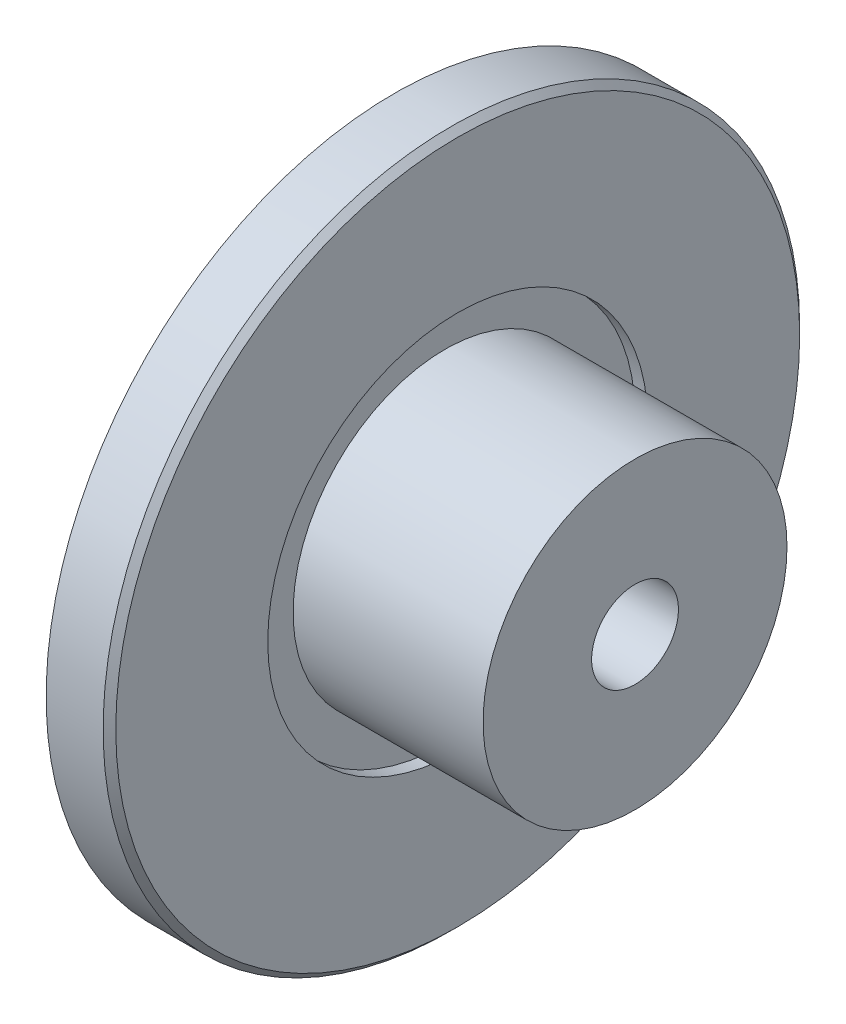
from build123d import *
from build123d.topology import SkipClean

# Parameters (mm, degrees)
SKETCH1_R               = 27.5
BOSS_EXTRUDE1_DEPTH     = 4
SKETCH2_R               = 27.5
SKETCH2_R_2             = 15
BOSS_EXTRUDE2_DEPTH     = 1
CUT_EXTRUDE1_DEPTH      = 40.210967853
CUT_EXTRUDE1_DEPTH_BACK = 40.210967853
SKETCH3_R               = 3.429
SKETCH4_R               = 12
SKETCH4_R_2             = 3.429
BOSS_EXTRUDE3_DEPTH     = 15
CHAMFER1_SIZE           = 0.5


with BuildPart() as part:
    # Sketch1 → Boss-Extrude1 (new body)
    with BuildSketch(Plane(origin=(0, 0, 0), x_dir=(0, 0, -1), z_dir=(1, 0, 0))):
        Circle(SKETCH1_R)
    extrude(amount=BOSS_EXTRUDE1_DEPTH)

    # Sketch2 → Boss-Extrude2 (add)
    with BuildSketch(Plane(origin=(4, 0, 0), x_dir=(0, 0, -1), z_dir=(1, 0, 0))):
        Circle(SKETCH2_R)
        Circle(SKETCH2_R_2, mode=Mode.SUBTRACT)
    extrude(amount=BOSS_EXTRUDE2_DEPTH)

    # Sketch3 → Cut-Extrude1 (cut, two sides: drawn at the far end of the back side and taken through both)
    with BuildSketch(Plane.ZY.offset(-CUT_EXTRUDE1_DEPTH_BACK)):
        Circle(SKETCH3_R)
    extrude(amount=CUT_EXTRUDE1_DEPTH + CUT_EXTRUDE1_DEPTH_BACK, mode=Mode.SUBTRACT)

    # Sketch4 → Boss-Extrude3 (add)
    with SkipClean():  # the faces are left unmerged after this step: merging them gives an invalid solid
        with BuildSketch(Plane(origin=(4, 0, 0), x_dir=(0, 0, -1), z_dir=(1, 0, 0))):
            Circle(SKETCH4_R)
            Circle(SKETCH4_R_2, mode=Mode.SUBTRACT)
        extrude(amount=BOSS_EXTRUDE3_DEPTH)

    # Chamfer1
    chamfer1_edges = [part.edges().sort_by_distance(p)[0] for p in [
        (5, 0, 27.5),
    ]]
    chamfer(chamfer1_edges, length=CHAMFER1_SIZE)


solid = part.part
